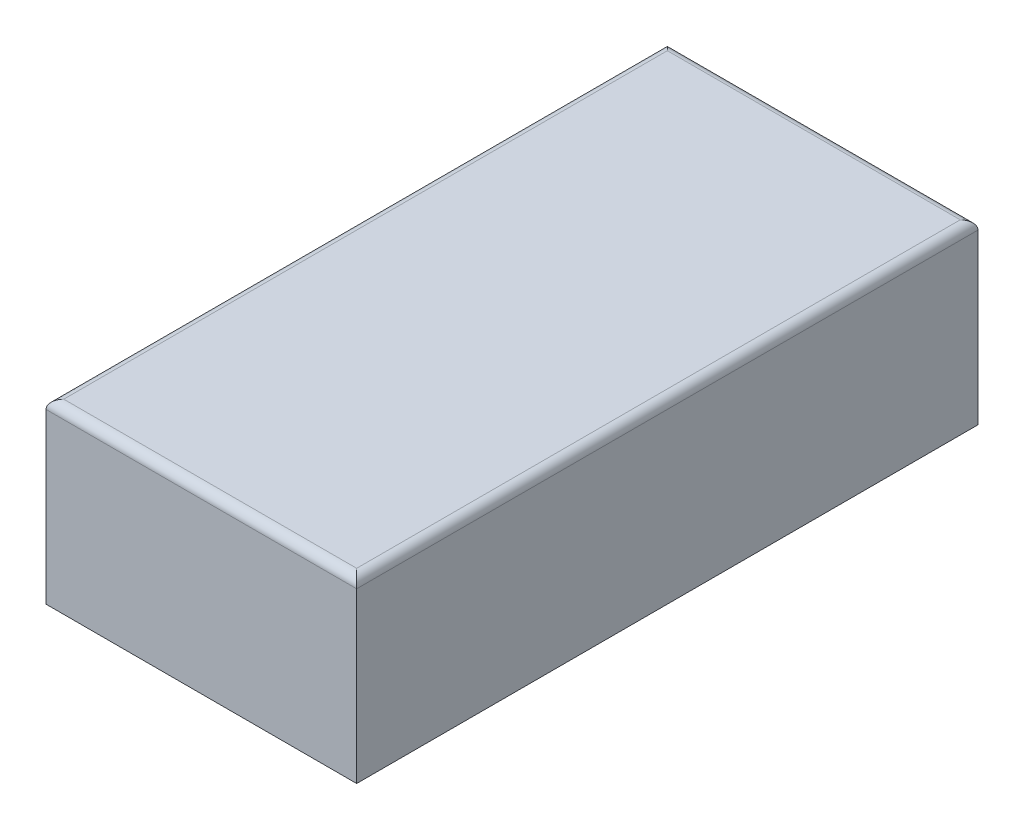
from build123d import *

# Parameters (mm, degrees)
SKETCH1_W           = 3.5
SKETCH1_H           = 7
BOSS_EXTRUDE1_DEPTH = 2
FILLET1_R           = 0.1


with BuildPart() as part:
    # Sketch1 → Boss-Extrude1 (new body)
    with BuildSketch(Plane(origin=(0, 0, 0), x_dir=(1, 0, 0), z_dir=(0, 1, 0))):
        with Locations((1.75, 3.5)):
            Rectangle(SKETCH1_W, SKETCH1_H)
    extrude(amount=BOSS_EXTRUDE1_DEPTH)

    # Fillet1
    fillet1_edges = [part.edges().sort_by_distance(p)[0] for p in [
        (3.5, 2, -3.5),
        (1.75, 2, -7),
        (0, 2, -3.5),
        (1.75, 2, 0),
    ]]
    fillet(fillet1_edges, radius=FILLET1_R)


solid = part.part
